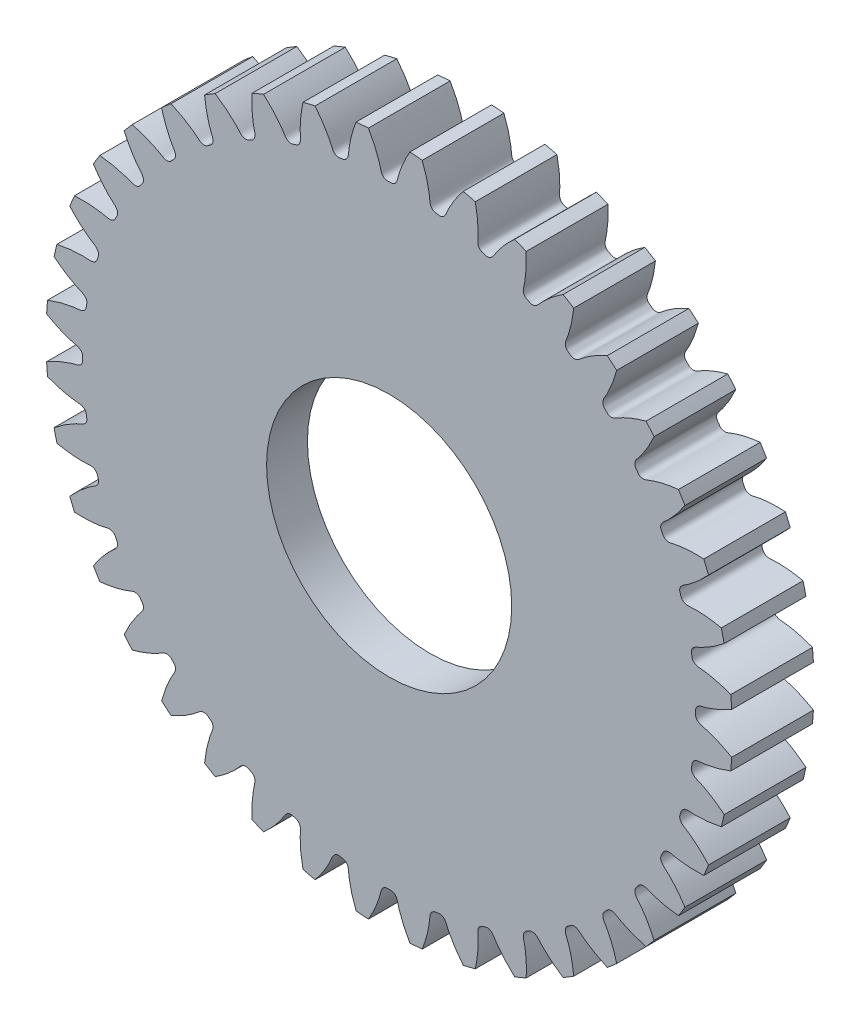
from build123d import *

# Parameters (mm, degrees)
SKETCHREVOLVEENGRANAJE_GRUESO_8_3_W       = 1
SKETCHREVOLVEENGRANAJE_GRUESO_8_3_H       = 4.2
TOOTHEXTRUDECUTENGRANAJE_GRUESO_8_3_DEPTH = 0.5
PATTERNENGRANAJE_GRUESO_8_3_COUNT         = 40
CROQUIS5_R                                = 1.5
CORTAR_EXTRUIR2_DEPTH                     = 10
CROQUIS6_R                                = 2.75
CORTAR_EXTRUIR3_DEPTH                     = 0.5


with BuildPart() as part:
    # SketchRevolveEngranaje Grueso_8.3 → Engranaje Grueso_8.3 (revolve)
    with BuildSketch(Plane(origin=(0, 0, 0), x_dir=(0, 0, -1), z_dir=(1, 0, 0))):
        with Locations((0, 2.1)):
            Rectangle(SKETCHREVOLVEENGRANAJE_GRUESO_8_3_W, SKETCHREVOLVEENGRANAJE_GRUESO_8_3_H)
    revolve(axis=Axis((0, 0, 0), (0, 0, -1)))

    # SketchToothEngranaje Grueso_8.3 → ToothExtrudeCutEngranaje Grueso_8.3 (cut, symmetric)
    with BuildSketch(Plane.XY):
        with BuildLine():
            ThreePointArc((4.20200942, 0.259262099), (4.21, 0), (4.20200942, -0.259262099))
            add(Edge.make_bspline(
                [(4.20200942, -0.259262099), (4.174496891, -0.243186587), (4.137967685, -0.223050908), (4.092305812, -0.200031579), (4.066798687, -0.187735102), (4.042151991, -0.176387474), (4.018391031, -0.16595417), (3.995540145, -0.156400035), (3.973622701, -0.147689375), (3.9526611, -0.139785871), (3.93267668, -0.13265295), (3.913690009, -0.126252612), (3.895719834, -0.120549559), (3.878786603, -0.115497243), (3.86290051, -0.111085182), (3.845072939, -0.106380855), (3.830764521, -0.103303012), (3.819981916, -0.100293169), (3.815196786, -0.09880564), (3.810488819, -0.097186273), (3.805842361, -0.095415225), (3.801238788, -0.093469315), (3.796657614, -0.091317101), (3.792076777, -0.088917335), (3.787474038, -0.086215737), (3.782829675, -0.083141439), (3.77813154, -0.079603091), (3.773383783, -0.075485753), (3.768620831, -0.07065094), (3.763927252, -0.064944342), (3.759461768, -0.058218315), (3.755473404, -0.050375271), (3.752301452, -0.041433921), (3.750380195, -0.03201569), (3.749597753, -0.018086181), (3.750286474, 0), (3.749597753, 0.018086181), (3.750380195, 0.03201569), (3.752301452, 0.041433921), (3.755473404, 0.050375271), (3.759461768, 0.058218315), (3.763927252, 0.064944342), (3.768620831, 0.07065094), (3.773383783, 0.075485753), (3.77813154, 0.079603091), (3.782829675, 0.083141439), (3.787474038, 0.086215737), (3.792076777, 0.088917335), (3.796657614, 0.091317101), (3.801238788, 0.093469315), (3.805842361, 0.095415225), (3.810488819, 0.097186273), (3.815196786, 0.09880564), (3.819981916, 0.100293169), (3.830764521, 0.103303012), (3.845072939, 0.106380855), (3.86290051, 0.111085182), (3.878786603, 0.115497243), (3.895719834, 0.120549559), (3.913690009, 0.126252612), (3.93267668, 0.13265295), (3.9526611, 0.139785871), (3.973622701, 0.147689375), (3.995540145, 0.156400035), (4.018391031, 0.16595417), (4.042151991, 0.176387474), (4.066798687, 0.187735102), (4.092305812, 0.200031579), (4.137967685, 0.223050908), (4.174496891, 0.243186587), (4.20200942, 0.259262099)],
                knots=[0, 0, 0, 0, 0.086796787, 0.113581779, 0.139292749, 0.163929698, 0.187492626, 0.209981533, 0.231396418, 0.251737282, 0.271004125, 0.289196946, 0.306315746, 0.322360525, 0.337331282, 0.351228018, 0.37258288, 0.377176197, 0.381719243, 0.386231527, 0.390736478, 0.39526235, 0.399843319, 0.404520783, 0.409344831, 0.414375717, 0.41968501, 0.42535569, 0.431479821, 0.438151626, 0.445453068, 0.453429786, 0.462059424, 0.471223273, 0.479505676, 0.5, 0.520494324, 0.528776727, 0.537940576, 0.546570214, 0.554546932, 0.561848374, 0.568520179, 0.57464431, 0.58031499, 0.585624283, 0.590655169, 0.595479217, 0.600156681, 0.60473765, 0.609263522, 0.613768473, 0.618280757, 0.622823803, 0.62741712, 0.648771982, 0.662668718, 0.677639475, 0.693684254, 0.710803054, 0.728995875, 0.748262718, 0.768603582, 0.790018467, 0.812507374, 0.836070302, 0.860707251, 0.886418221, 0.913203213, 1, 1, 1, 1], degree=3))
        make_face()
    toothextrudecutengranaje_grueso_8_3 = extrude(amount=TOOTHEXTRUDECUTENGRANAJE_GRUESO_8_3_DEPTH, both=True, mode=Mode.SUBTRACT)

    # PatternEngranaje Grueso_8.3: ToothExtrudeCutEngranaje Grueso_8.3 ×40 about axis
    patternengranaje_grueso_8_3_axis = Axis((0, 0, 55), (0, 0, -1))
    for i in range(1, PATTERNENGRANAJE_GRUESO_8_3_COUNT):
        add(toothextrudecutengranaje_grueso_8_3.rotate(patternengranaje_grueso_8_3_axis, i * 360 / PATTERNENGRANAJE_GRUESO_8_3_COUNT), mode=Mode.SUBTRACT)

    # Croquis5 → Cortar-Extruir2 (cut)
    with BuildSketch(Plane.XY.offset(0.5)):
        Circle(CROQUIS5_R)
    extrude(amount=-CORTAR_EXTRUIR2_DEPTH, mode=Mode.SUBTRACT)

    # Croquis6 → Cortar-Extruir3 (cut)
    with BuildSketch(Plane(origin=(0, 0, -0.5), x_dir=(-1, 0, 0), z_dir=(0, 0, -1))):
        Circle(CROQUIS6_R)
    extrude(amount=-CORTAR_EXTRUIR3_DEPTH, mode=Mode.SUBTRACT)


solid = part.part
